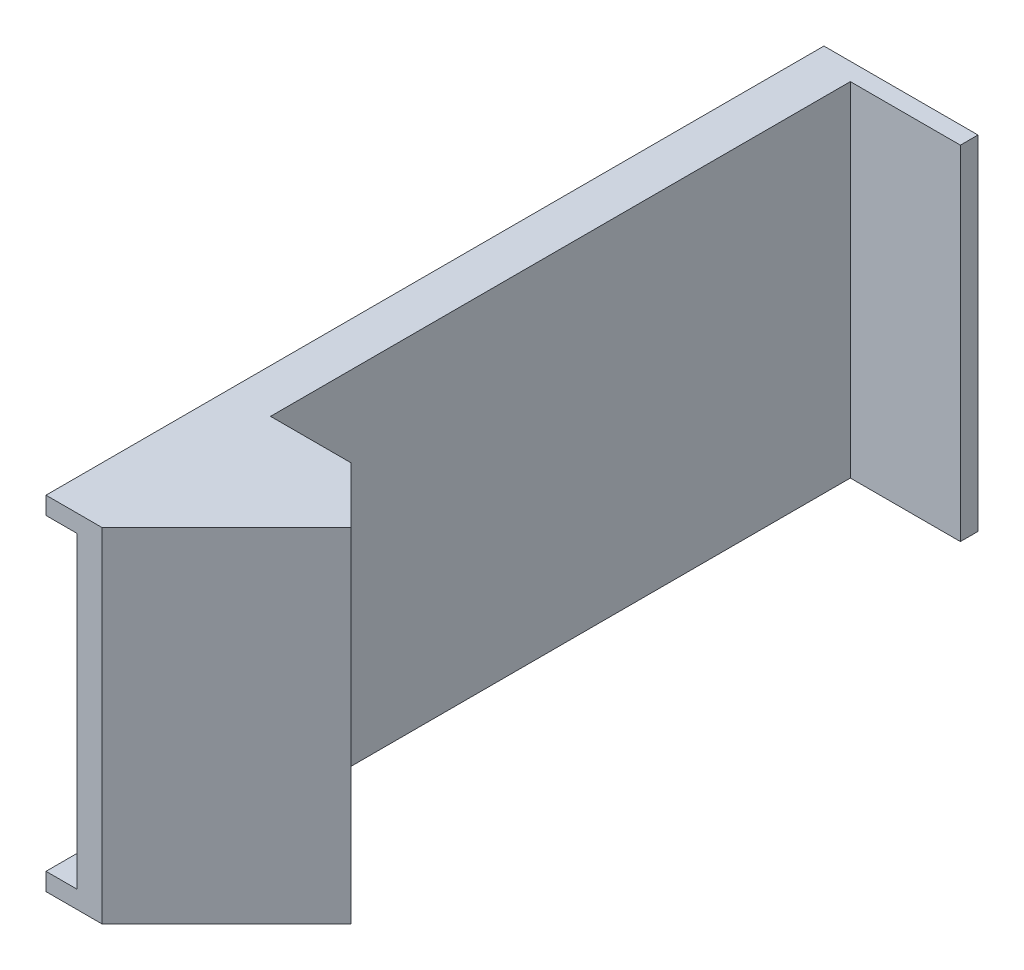
from build123d import *

# Parameters (mm, degrees)
SKETCH1_W           = 30
SKETCH1_H           = 39
BOSS_EXTRUDE1_DEPTH = 2
SKETCH2_W           = 5
SKETCH2_H           = 39
BOSS_EXTRUDE2_DEPTH = 80
CUT_EXTRUDE1_DEPTH  = 39
SKETCH4_W           = 20
SKETCH4_H           = 39
BOSS_EXTRUDE3_DEPTH = 9
SKETCH5_W           = 5
SKETCH5_H           = 35
CUT_EXTRUDE2_DEPTH  = 30
SKETCH6_W           = 12.5
SKETCH6_H           = 39
CUT_EXTRUDE3_DEPTH  = 2
BOSS_EXTRUDE4_DEPTH = 39
BOSS_EXTRUDE5_DEPTH = 39
SKETCH10_W          = 5
SKETCH10_H          = 35
CUT_EXTRUDE4_DEPTH  = 10


with BuildPart() as part:
    # Sketch1 → Boss-Extrude1 (new body)
    with BuildSketch(Plane.XY):
        Rectangle(SKETCH1_W, SKETCH1_H)
    extrude(amount=BOSS_EXTRUDE1_DEPTH)

    # Sketch2 → Boss-Extrude2 (add)
    with BuildSketch(Plane.XY.offset(2)):
        Rectangle(SKETCH2_W, SKETCH2_H)
    extrude(amount=BOSS_EXTRUDE2_DEPTH)

    # Sketch3 → Cut-Extrude1 (cut)
    with BuildSketch(Plane.XZ.offset(19.5)):
        Polygon((-2.5, 82), (2.5, 82), (2.5, 77), align=None)
    extrude(amount=-CUT_EXTRUDE1_DEPTH, mode=Mode.SUBTRACT)

    # Sketch4 → Boss-Extrude3 (add)
    with BuildSketch(Plane(origin=(39.75, 0, 39.75), x_dir=(0.707106781, 0, -0.707106781), z_dir=(0.707106781, 0, 0.707106781))):
        with Locations((-49.75052301, 0)):
            Rectangle(SKETCH4_W, SKETCH4_H)
    extrude(amount=BOSS_EXTRUDE3_DEPTH)

    # Sketch5 → Cut-Extrude2 (cut)
    with BuildSketch(Plane(origin=(-28.107864376, 0, 28.107864376), x_dir=(-0.707106781, 0, -0.707106781), z_dir=(0.707106781, 0, -0.707106781))):
        with Locations((-60.714989104, 0)):
            Rectangle(SKETCH5_W, SKETCH5_H)
    extrude(amount=-CUT_EXTRUDE2_DEPTH, mode=Mode.SUBTRACT)

    # Sketch6 → Cut-Extrude3 (cut)
    with BuildSketch(Plane.XY.offset(2)):
        with Locations((-8.75, 0)):
            Rectangle(SKETCH6_W, SKETCH6_H)
    extrude(amount=-CUT_EXTRUDE3_DEPTH, mode=Mode.SUBTRACT)

    # Sketch7 → Boss-Extrude4 (add)
    with BuildSketch(Plane.XZ.offset(19.5)):
        Polygon((-2.5, 82), (3.863961031, 88.363961031), (-2.5, 88.363961031), align=None)
    extrude(amount=-BOSS_EXTRUDE4_DEPTH)

    # Sketch8 → Boss-Extrude5 (add)
    with BuildSketch(Plane.XZ.offset(19.5)):
        Polygon((2.5, 77), (11.642135624, 67.857864376), (2.5, 67.857864376), align=None)
    extrude(amount=-BOSS_EXTRUDE5_DEPTH)

    # Sketch10 → Cut-Extrude4 (cut)
    with BuildSketch(Plane(origin=(-42.25, 0, 42.25), x_dir=(-0.707106781, 0, -0.707106781), z_dir=(0.707106781, 0, -0.707106781))):
        with Locations((-60.714989104, 0)):
            Rectangle(SKETCH10_W, SKETCH10_H)
    extrude(amount=-CUT_EXTRUDE4_DEPTH, mode=Mode.SUBTRACT)


solid = part.part
